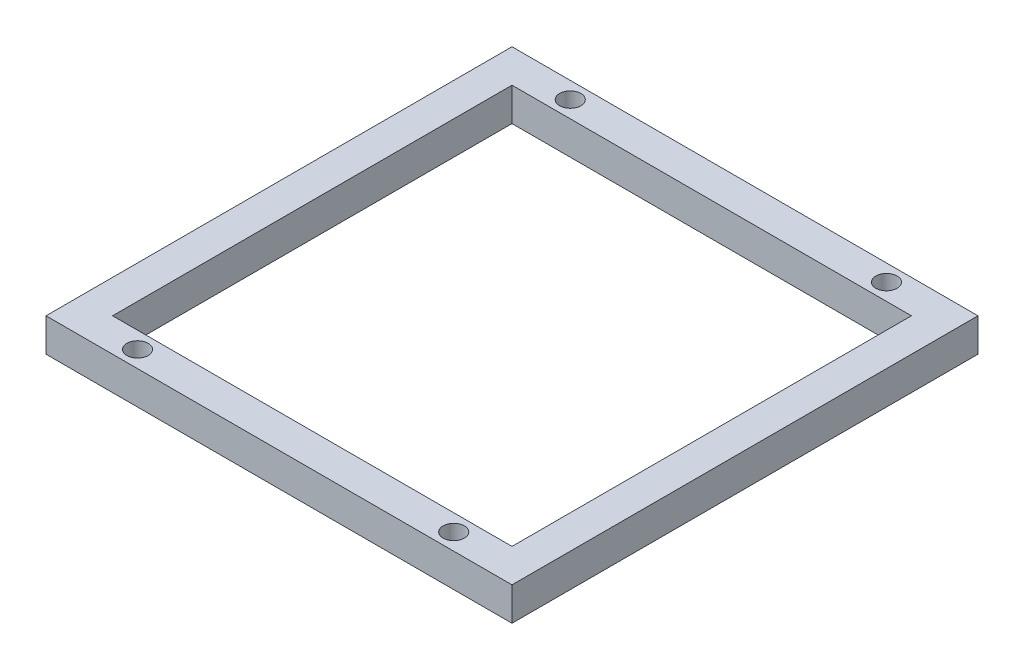
from build123d import *

# Parameters (mm, degrees)
SKETCH1_W           = 70
SKETCH1_H           = 70
SKETCH1_R           = 1.6
SKETCH1_W_2         = 60
SKETCH1_H_2         = 60
BOSS_EXTRUDE1_DEPTH = 2.5


with BuildPart() as part:
    # Sketch1 → Boss-Extrude1 (new body, symmetric)
    with BuildSketch(Plane(origin=(0, 0, 0), x_dir=(1, 0, 0), z_dir=(0, 1, 0))):
        Rectangle(SKETCH1_W, SKETCH1_H)
        with Locations((-23.75, 32.5)):
            Circle(SKETCH1_R, mode=Mode.SUBTRACT)
        with Locations((23.75, 32.5)):
            Circle(SKETCH1_R, mode=Mode.SUBTRACT)
        with Locations((23.75, -32.5)):
            Circle(SKETCH1_R, mode=Mode.SUBTRACT)
        with Locations((-23.75, -32.5)):
            Circle(SKETCH1_R, mode=Mode.SUBTRACT)
        Rectangle(SKETCH1_W_2, SKETCH1_H_2, mode=Mode.SUBTRACT)
    extrude(amount=BOSS_EXTRUDE1_DEPTH, both=True)


solid = part.part
